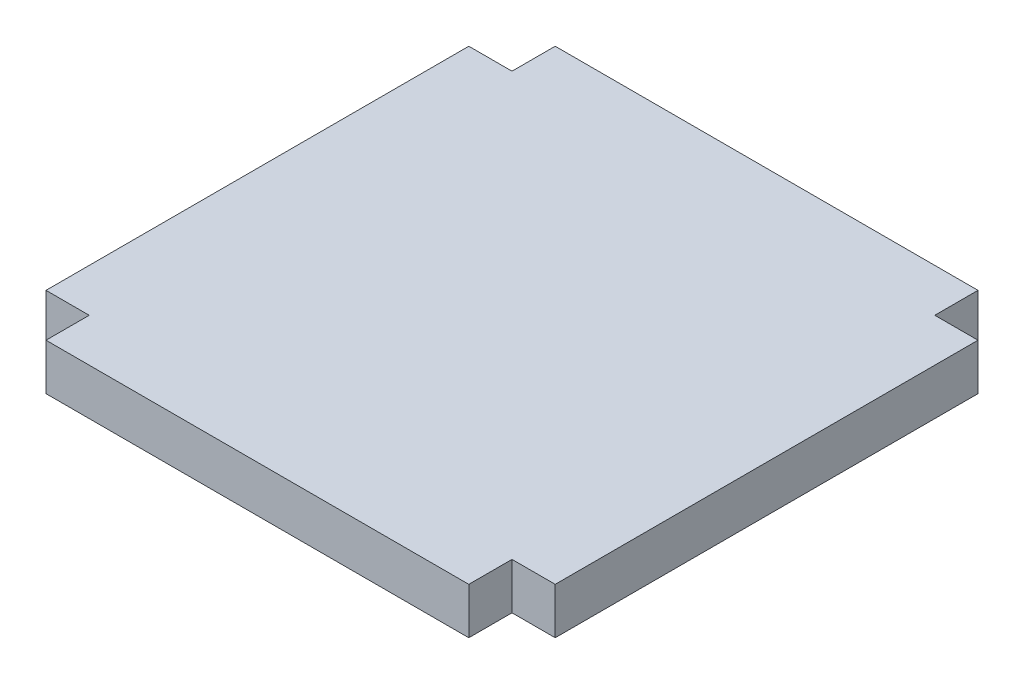
from build123d import *

# Parameters (mm, degrees)
BOSS_EXTRUDE1_DEPTH = 19.05


with BuildPart() as part:
    # Sketch1 → Boss-Extrude1 (new body)
    with BuildSketch(Plane(origin=(0, 0, 0), x_dir=(1, 0, 0), z_dir=(0, 1, 0))):
        Polygon((86.995, 104.775), (-86.995, 104.775), (-86.995, 86.995), (-104.775, 86.995), (-104.775, -86.995), (-86.995, -86.995), (-86.995, -104.775), (86.995, -104.775), (86.995, -86.995), (104.775, -86.995), (104.775, 86.995), (86.995, 86.995), align=None)
    extrude(amount=BOSS_EXTRUDE1_DEPTH)


solid = part.part
